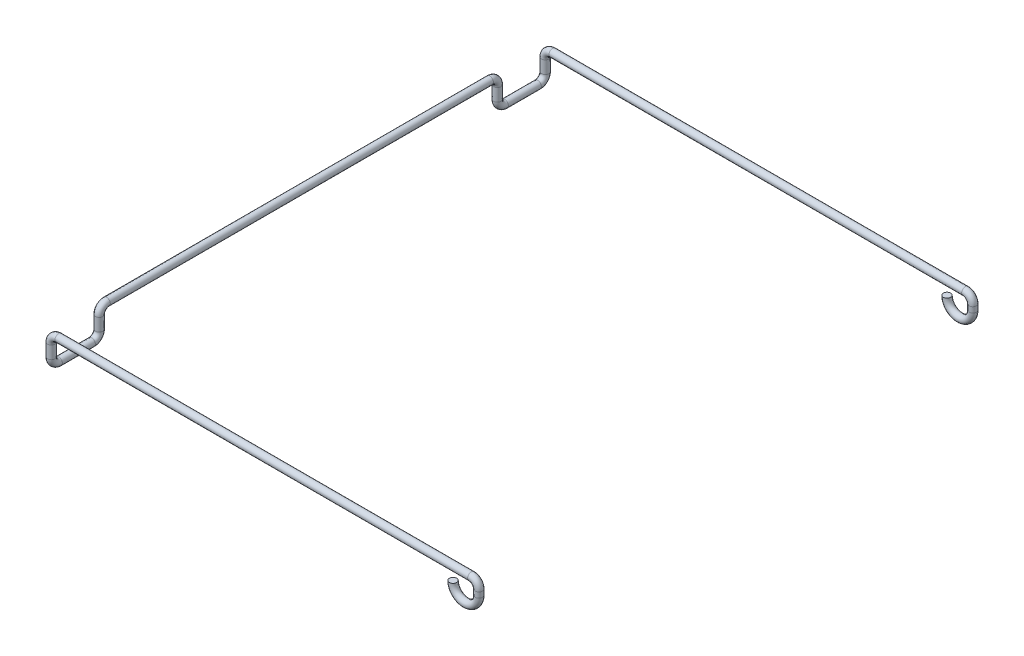
from build123d import *

# Parameters (mm, degrees)
SKETCH_1_R = 0.5


with BuildPart() as part:
    # 扫描1: sweep along a curve in space
    with BuildLine() as sweep_1_path:
        ThreePointArc((45.921476331, -1.752944525, -33.5), (47.672946117, -3.499999381, -33.5), (49.421473853, -1.75, -33.5))
        Line((49.421473853, -1.013038035, -33.5), (49.421473853, -1.75, -33.5))
        ThreePointArc((49.421473853, -1.013038035, -33.5), (49.124761883, -0.296711971, -33.5), (48.408435819, 0, -33.5))
        Line((-7.565488112, 0, -33.5), (48.408435819, 0, -33.5))
        ThreePointArc((-8.578526147, -1.013038035, -33.5), (-8.281814176, -0.296711971, -33.5), (-7.565488112, 0, -33.5))
        Line((-8.578526147, -1.013038035, -33.5), (-8.578526147, -2.736961965, -33.5))
        ThreePointArc((-8.578526147, -3.75, -32.486961965), (-8.578526147, -3.453288029, -33.203288029), (-8.578526147, -2.736961965, -33.5))
        Line((-8.578526147, -3.75, -32.486961965), (-8.578526147, -3.75, -28.013038035))
        ThreePointArc((-8.578526147, -2.736961965, -27), (-8.578526147, -3.453288029, -27.296711971), (-8.578526147, -3.75, -28.013038035))
        Line((-8.578526147, -2.736961965, -27), (-8.578526147, -1.013038035, -27))
        ThreePointArc((-8.578526147, 0, -25.986961965), (-8.578526147, -0.296711971, -26.703288029), (-8.578526147, -1.013038035, -27))
        Line((-8.578526147, 0, -25.986961965), (-8.578526147, 0, 25.986961965))
        ThreePointArc((-8.578526147, -1.013038035, 27), (-8.578526147, -0.296711971, 26.703288029), (-8.578526147, 0, 25.986961965))
        Line((-8.578526147, -2.736961965, 27), (-8.578526147, -1.013038035, 27))
        ThreePointArc((-8.578526147, -3.75, 28.013038035), (-8.578526147, -3.453288029, 27.296711971), (-8.578526147, -2.736961965, 27))
        Line((-8.578526147, -3.75, 28.013038035), (-8.578526147, -3.75, 32.486961965))
        ThreePointArc((-8.578526147, -2.736961965, 33.5), (-8.578526147, -3.453288029, 33.203288029), (-8.578526147, -3.75, 32.486961965))
        Line((-8.578526147, -1.013038035, 33.5), (-8.578526147, -2.736961965, 33.5))
        ThreePointArc((-8.578526147, -1.013038035, 33.5), (-8.281814176, -0.296711971, 33.5), (-7.565488112, 0, 33.5))
        Line((-7.565488112, 0, 33.5), (48.408435819, 0, 33.5))
        ThreePointArc((48.408435819, 0, 33.5), (49.124761883, -0.296711971, 33.5), (49.421473853, -1.013038035, 33.5))
        Line((49.421473853, -1.013038035, 33.5), (49.421473853, -1.75, 33.5))
        ThreePointArc((45.921473853, -1.75, 33.5), (47.671473853, -3.5, 33.5), (49.421473853, -1.75, 33.5))
    # 草图1 → 扫描1 (sweep)
    with BuildSketch(Plane.XY):
        with Locations((-8.578526147, 0)):
            Circle(SKETCH_1_R)
    sweep(path=sweep_1_path.line)


solid = part.part
